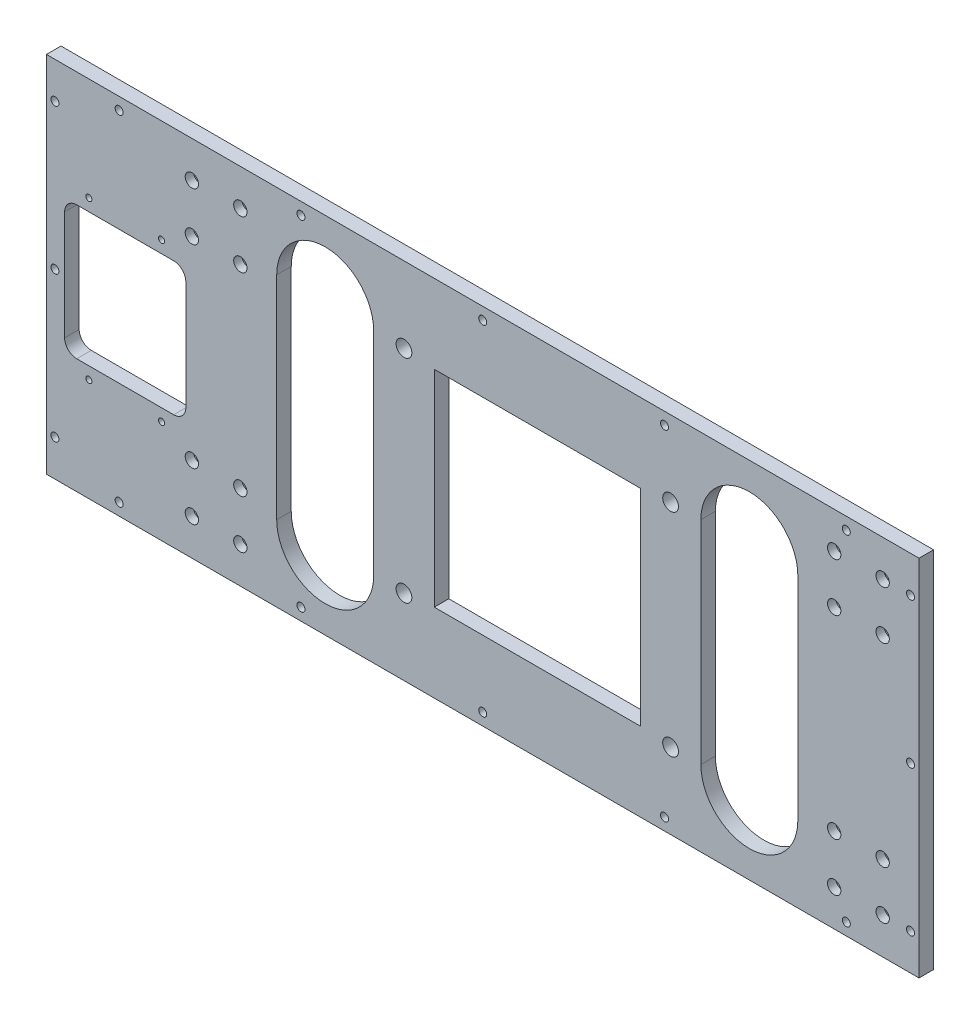
from build123d import *

# Parameters (mm, degrees)
SKETCH_1_W                  = 720
SKETCH_1_H                  = 300
EXTRUDE_1_DEPTH             = 6
SKETCH_2_R                  = 30
CUT_EXTRUDE_1_DEPTH         = 13
SKETCH_5_R                  = 22.5
CUT_EXTRUDE_2_DEPTH         = 13
HOLE_WIZARD_M6_1_D          = 5
HOLE_WIZARD_13_0_13_1_D     = 13
HOLE_WIZARD_4_D             = 6.6
HOLE_WIZARD_4_CBORE_D       = 11
HOLE_WIZARD_4_CBORE_DEPTH   = 6.8
HOLE_WIZARD_11_0_11_1_D     = 11
HOLE_WIZARD_11_0_11_2_D     = 11
SKETCH_29_W                 = 170
SKETCH_29_H                 = 170
CUT_EXTRUDE_5_DEPTH         = 13
CUT_EXTRUDE_6_DEPTH         = 13
HOLE_WIZARD_M5_3_D          = 4.2
SKETCH_32_R                 = 28
CUT_EXTRUDE_7_DEPTH         = 13
HOLE_WIZARD_4_2_D           = 6.6
HOLE_WIZARD_4_2_CBORE_D     = 11
HOLE_WIZARD_4_2_CBORE_DEPTH = 6.8
HOLE_WIZARD_M6_2_D          = 5
SKETCH_38_W                 = 100
SKETCH_38_H                 = 110
CUT_EXTRUDE_8_DEPTH         = 13
HOLE_WIZARD_M6_3_D          = 5
FILLET_1_R                  = 10


with BuildPart() as part:
    # 草图1 → 凸台-拉伸1 (new body, symmetric)
    with BuildSketch(Plane.XY):
        Rectangle(SKETCH_1_W, SKETCH_1_H)
    extrude(amount=EXTRUDE_1_DEPTH, both=True)

    # 草图2 → 切除-拉伸1 (cut, through all)
    with BuildSketch(Plane.XY.offset(6)):
        with Locations((45, 0)):
            Circle(SKETCH_2_R)
    extrude(amount=-CUT_EXTRUDE_1_DEPTH, mode=Mode.SUBTRACT)

    # 草图5 → 切除-拉伸2 (cut, through all)
    with BuildSketch(Plane.XY.offset(6)):
        with Locations((-130, 87.5)):
            Circle(SKETCH_5_R)
        with Locations((-130, -87.5)):
            Circle(SKETCH_5_R)
        with Locations((220, -87.5)):
            Circle(SKETCH_5_R)
        with Locations((220, 87.5)):
            Circle(SKETCH_5_R)
    extrude(amount=-CUT_EXTRUDE_2_DEPTH, mode=Mode.SUBTRACT)

    # M6 螺纹孔1 (through all)
    with Locations(Plane.XY.offset(6)):
        with Locations((-154.5, -105), (-154.5, 105), (-105.5, 105), (-105.5, 70), (-154.5, 70), (244.5, 70), (195.5, 70), (195.5, 105), (244.5, 105), (244.5, -105), (195.5, -105), (195.5, -70), (244.5, -70), (-154.5, -70), (-105.5, -70), (-105.5, -105)):
            Hole(HOLE_WIZARD_M6_1_D / 2)

    # Ø13.0 (13) 直径孔1 (through all)
    with Locations(Plane.XY.offset(6)):
        with Locations((-65, 87.5), (155, 87.5), (155, -87.5), (-65, -87.5)):
            Hole(HOLE_WIZARD_13_0_13_1_D / 2)

    # Hole Wizard 4 (through all)
    with Locations(Plane(origin=(-240, 120, 6), x_dir=(1, 0, 0), z_dir=(0, 0, 1))):
        with Locations((0, 0), (40, 0), (40, -40), (0, -40), (40, -200), (40, -240), (0, -240), (0, -200), (530, 0), (570, 0), (570, -40), (530, -40), (530, -200), (570, -200), (570, -240), (530, -240)):
            CounterBoreHole(HOLE_WIZARD_4_D / 2, HOLE_WIZARD_4_CBORE_D / 2, HOLE_WIZARD_4_CBORE_DEPTH)

    # Ø11.0 (11) 直径孔1 (through all)
    with Locations(Plane(origin=(-30, 75, 6), x_dir=(1, 0, 0), z_dir=(0, 0, 1))):
        with Locations((0, 0), (152.597951226, 3.193252991), (0, -150), (150, -150)):
            Hole(HOLE_WIZARD_11_0_11_1_D / 2)

    # Ø11.0 (11) 直径孔2 (through all)
    with Locations(Plane(origin=(0.5, -44.5, 6), x_dir=(1, 0, 0), z_dir=(0, 0, 1))):
        with Locations((0, 0), (89, 0), (89, 89), (0, 89)):
            Hole(HOLE_WIZARD_11_0_11_2_D / 2)

    # 草图29 → 切除-拉伸5 (cut, through all)
    with BuildSketch(Plane.XY.offset(6)):
        with Locations((45, 0)):
            Rectangle(SKETCH_29_W, SKETCH_29_H)
    extrude(amount=-CUT_EXTRUDE_5_DEPTH, mode=Mode.SUBTRACT)

    # 草图30 → 切除-拉伸6 (cut, through all)
    with BuildSketch(Plane.XY.offset(6)):
        with BuildLine():
            Line((-90, 87.5), (-90, -87.5))
            ThreePointArc((-90, -87.5), (-130, -127.5), (-170, -87.5))
            Line((-170, -87.5), (-170, 87.5))
            ThreePointArc((-170, 87.5), (-130, 127.5), (-90, 87.5))
        make_face()
        with BuildLine():
            Line((260, 87.5), (260, -87.5))
            ThreePointArc((260, -87.5), (220, -127.5), (180, -87.5))
            Line((180, -87.5), (180, 87.5))
            ThreePointArc((180, 87.5), (220, 127.5), (260, 87.5))
        make_face()
    extrude(amount=-CUT_EXTRUDE_6_DEPTH, mode=Mode.SUBTRACT)

    # M5 螺纹孔3 (through all)
    with Locations(Plane(origin=(-336.75, 24.75, 6), x_dir=(1, 0, 0), z_dir=(0, 0, 1))):
        with Locations((0, 0), (49.5, 0), (49.5, -49.5), (0, -49.5)):
            Hole(HOLE_WIZARD_M5_3_D / 2)

    # 草图32 → 切除-拉伸7 (cut, through all)
    with BuildSketch(Plane.XY.offset(6)):
        with Locations((-312, 0)):
            Circle(SKETCH_32_R)
    extrude(amount=-CUT_EXTRUDE_7_DEPTH, mode=Mode.SUBTRACT)

    # Hole Wizard 4 2 (through all)
    with Locations(Plane(origin=(-353, -120, -6), x_dir=(-1, 0, 0), z_dir=(0, 0, -1))):
        with Locations((0, 0), (0, 120), (0, 240), (-53, 260), (-203, 260), (-353, 260), (-503, 260), (-653, 260), (-706, 240), (-706, 120), (-706, 0), (-653, -20), (-503, -20), (-353, -20), (-203, -20), (-53, -20)):
            CounterBoreHole(HOLE_WIZARD_4_2_D / 2, HOLE_WIZARD_4_2_CBORE_D / 2, HOLE_WIZARD_4_2_CBORE_DEPTH)

    # M6 螺纹孔2 (through all)
    with Locations(Plane(origin=(-341.8, 34.8, 6), x_dir=(1, 0, 0), z_dir=(0, 0, 1))):
        with Locations((0, 0), (69.6, 0), (69.6, -69.6), (0, -69.6)):
            Hole(HOLE_WIZARD_M6_2_D / 2)

    # 草图38 → 切除-拉伸8 (cut, through all)
    with BuildSketch(Plane.XY.offset(6)):
        with Locations((-295, 0)):
            Rectangle(SKETCH_38_W, SKETCH_38_H)
    extrude(amount=-CUT_EXTRUDE_8_DEPTH, mode=Mode.SUBTRACT)

    # M6 螺纹孔3 (through all)
    with Locations(Plane(origin=(-325, 65, 6), x_dir=(1, 0, 0), z_dir=(0, 0, 1))):
        with Locations((0, 0), (60, 0), (60, -130), (0, -130)):
            Hole(HOLE_WIZARD_M6_3_D / 2)

    # 圆角1
    fillet_1_edges = [part.edges().sort_by_distance(p)[0] for p in [
        (-245, 55, 0),
        (-245, -55, 0),
        (-345, -55, 0),
        (-345, 55, 0),
    ]]
    fillet(fillet_1_edges, radius=FILLET_1_R)


solid = part.part
